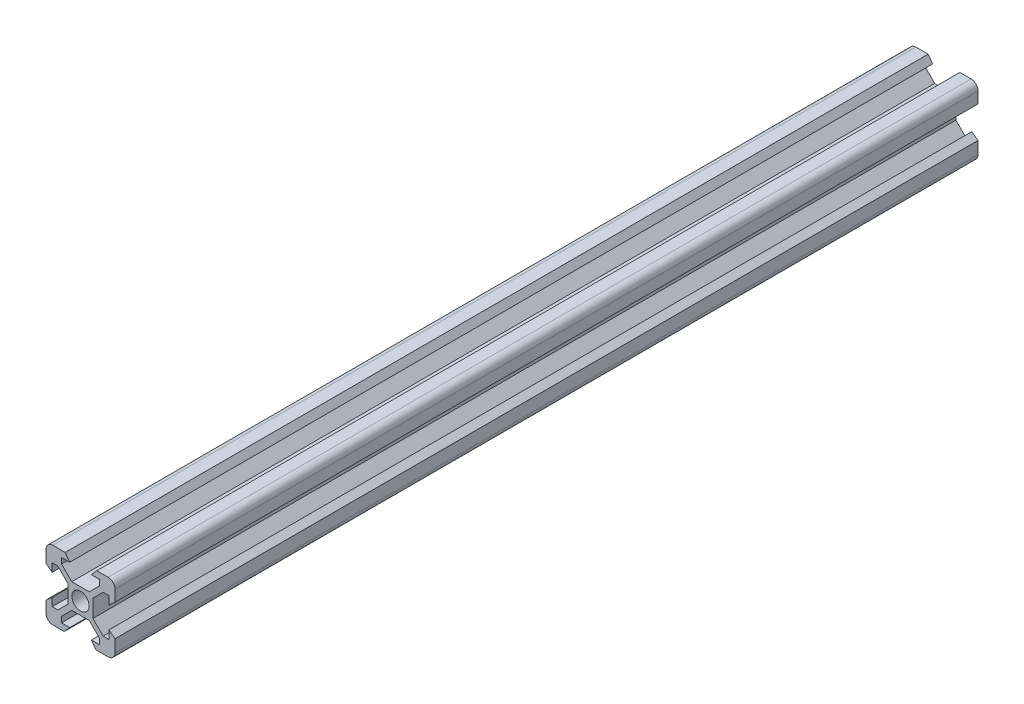
from build123d import *

# Parameters (mm, degrees)
SKETCH1_R           = 2.5
BOSS_EXTRUDE1_DEPTH = 250


with BuildPart() as part:
    # Sketch1 → Boss-Extrude1 (new body)
    with BuildSketch(Plane.XY):
        with BuildLine():
            Line((-4.725542729, -10), (-3.125, -8.2))
            Line((-3.125, -8.2), (-5.5, -8.2))
            Line((-5.5, -8.2), (-5.5, -6.560660172))
            Line((-5.5, -6.560660172), (-2.539339828, -3.6))
            Line((-2.539339828, -3.6), (2.539339828, -3.6))
            Line((2.539339828, -3.6), (5.5, -6.560660172))
            Line((5.5, -6.560660172), (5.5, -8.2))
            Line((5.5, -8.2), (3.125, -8.2))
            Line((3.125, -8.2), (4.434457271, -10))
            Line((4.434457271, -10), (8, -10))
            ThreePointArc((8, -10), (9.414213562, -9.414213562), (10, -8))
            Line((10, -8), (10, -4.434457271))
            Line((10, -4.434457271), (8.2, -3.125))
            Line((8.2, -3.125), (8.2, -5.5))
            Line((8.2, -5.5), (6.560660172, -5.5))
            Line((6.560660172, -5.5), (3.6, -2.539339828))
            Line((3.6, -2.539339828), (3.6, 2.539339828))
            Line((3.6, 2.539339828), (6.560660172, 5.5))
            Line((6.560660172, 5.5), (8.2, 5.5))
            Line((8.2, 5.5), (8.2, 3.125))
            Line((8.2, 3.125), (10, 4.725542729))
            Line((10, 4.725542729), (10, 8))
            ThreePointArc((10, 8), (9.414213562, 9.414213562), (8, 10))
            Line((8, 10), (4.725542729, 10))
            Line((4.725542729, 10), (3.125, 8.2))
            Line((3.125, 8.2), (5.5, 8.2))
            Line((5.5, 8.2), (5.5, 6.560660172))
            Line((5.5, 6.560660172), (2.539339828, 3.6))
            Line((2.539339828, 3.6), (-2.539339828, 3.6))
            Line((-2.539339828, 3.6), (-5.5, 6.560660172))
            Line((-5.5, 6.560660172), (-5.5, 8.2))
            Line((-5.5, 8.2), (-3.125, 8.2))
            Line((-3.125, 8.2), (-4.434457271, 10))
            Line((-4.434457271, 10), (-8, 10))
            ThreePointArc((-8, 10), (-9.414213562, 9.414213562), (-10, 8))
            Line((-10, 8), (-10, 4.434457271))
            Line((-10, 4.434457271), (-8.2, 3.125))
            Line((-8.2, 3.125), (-8.2, 5.5))
            Line((-8.2, 5.5), (-6.560660172, 5.5))
            Line((-6.560660172, 5.5), (-3.6, 2.539339828))
            Line((-3.6, 2.539339828), (-3.6, -2.539339828))
            Line((-3.6, -2.539339828), (-6.560660172, -5.5))
            Line((-6.560660172, -5.5), (-8.2, -5.5))
            Line((-8.2, -5.5), (-8.2, -3.125))
            Line((-8.2, -3.125), (-10, -4.725542729))
            Line((-10, -4.725542729), (-10, -8))
            ThreePointArc((-10, -8), (-9.414213562, -9.414213562), (-8, -10))
            Line((-8, -10), (-4.725542729, -10))
        make_face()
        Circle(SKETCH1_R, mode=Mode.SUBTRACT)
    extrude(amount=BOSS_EXTRUDE1_DEPTH)


solid = part.part
